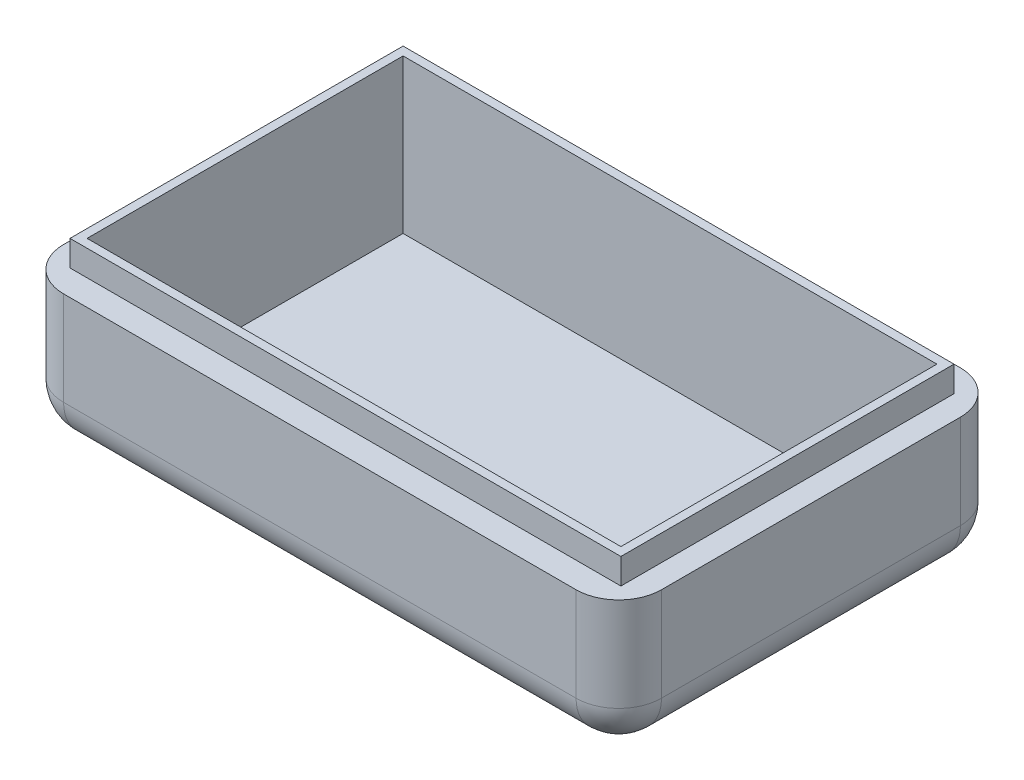
from build123d import *

# Parameters (mm, degrees)
SKETCH_1_W      = 64.5
SKETCH_1_H      = 39
SKETCH_1_W_2    = 62.5
SKETCH_1_H_2    = 37
EXTRUDE_2_DEPTH = 3
SKETCH_2_W      = 70
SKETCH_2_H      = 45
SKETCH_2_W_2    = 62.5
SKETCH_2_H_2    = 37
EXTRUDE_3_DEPTH = 15
SKETCH_4_W      = 70
SKETCH_4_H      = 1
EXTRUDE_4_DEPTH = 22.5
FILLET_1_R      = 5
FILLET_2_R      = 5


with BuildPart() as part:
    # 草图1 → 凸台-拉伸2 (new body)
    with BuildSketch(Plane(origin=(0, 0, 0), x_dir=(1, 0, 0), z_dir=(0, 1, 0))):
        Rectangle(SKETCH_1_W, SKETCH_1_H)
        Rectangle(SKETCH_1_W_2, SKETCH_1_H_2, mode=Mode.SUBTRACT)
    extrude(amount=EXTRUDE_2_DEPTH)

    # 草图2 → 凸台-拉伸3 (add)
    with BuildSketch(Plane(origin=(0, 0, 0), x_dir=(1, 0, 0), z_dir=(0, 1, 0))):
        Rectangle(SKETCH_2_W, SKETCH_2_H)
        Rectangle(SKETCH_2_W_2, SKETCH_2_H_2, mode=Mode.SUBTRACT)
    extrude(amount=-EXTRUDE_3_DEPTH)

    # 草图4 → 凸台-拉伸4 (add, symmetric)
    with BuildSketch(Plane.XY):
        with Locations((0, -15.5)):
            Rectangle(SKETCH_4_W, SKETCH_4_H)
    extrude(amount=EXTRUDE_4_DEPTH, both=True)

    # 圆角1
    fillet_1_edges = [part.edges().sort_by_distance(p)[0] for p in [
        (35, -8, -22.5),
        (35, -8, 22.5),
        (-35, -8, 22.5),
        (-35, -8, -22.5),
    ]]
    fillet(fillet_1_edges, radius=FILLET_1_R)

    # 圆角2
    fillet_2_edges = [part.edges().sort_by_distance(p)[0] for p in [
        (0, -16, 22.5),
        (35, -16, 0),
        (0, -16, -22.5),
        (-35, -16, 0),
        (-33.535533906, -16, -21.035533906),
        (-33.535533906, -16, 21.035533906),
        (33.535533906, -16, -21.035533906),
        (33.535533906, -16, 21.035533906),
    ]]
    fillet(fillet_2_edges, radius=FILLET_2_R)


solid = part.part
